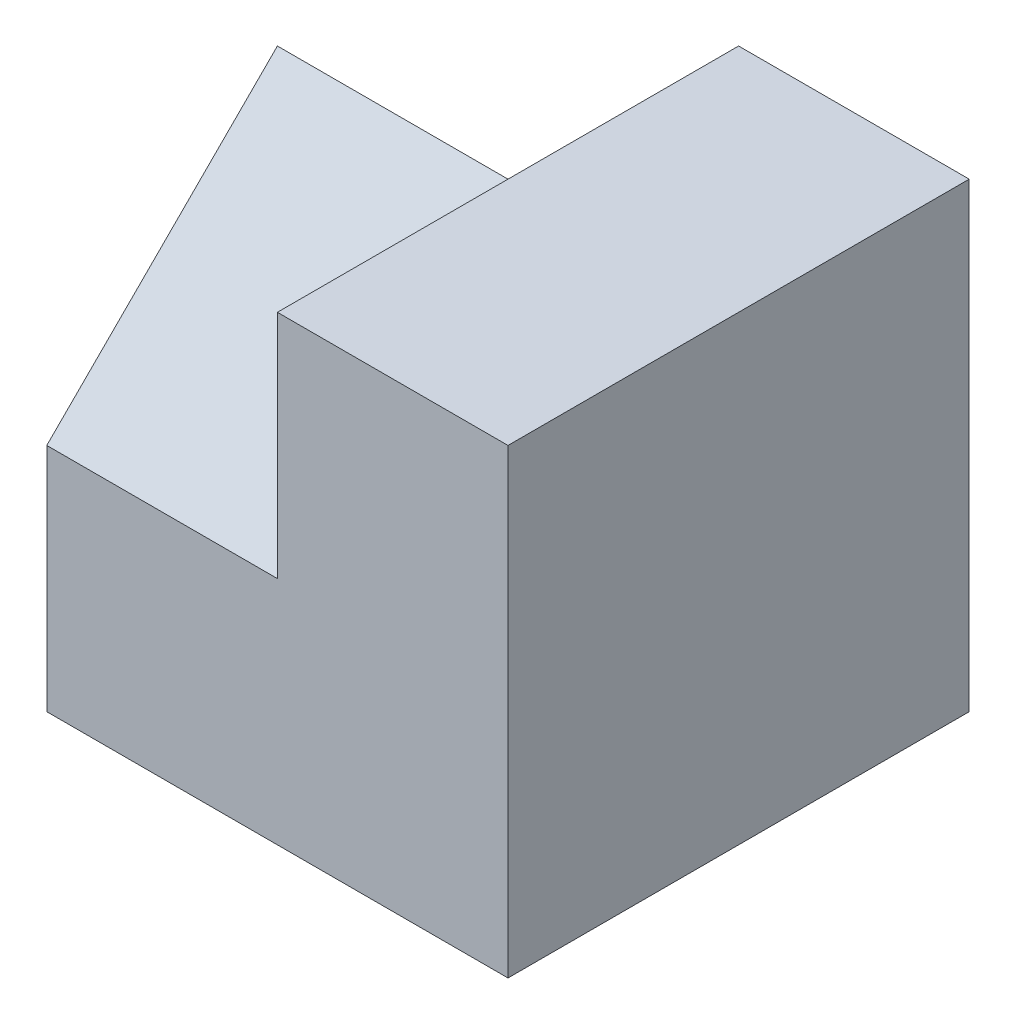
from build123d import *

# Parameters (mm, degrees)
SKETCH1_W           = 4
SKETCH1_H           = 4
BOSS_EXTRUDE1_DEPTH = 4
CUT_EXTRUDE1_DEPTH  = 2


with BuildPart() as part:
    # Sketch1 → Boss-Extrude1 (new body)
    with BuildSketch(Plane(origin=(0, 0, 0), x_dir=(1, 0, 0), z_dir=(0, 1, 0))):
        Rectangle(SKETCH1_W, SKETCH1_H)
    extrude(amount=BOSS_EXTRUDE1_DEPTH)

    # Sketch2 → Cut-Extrude1 (cut)
    with BuildSketch(Plane.ZY.offset(2)):
        Polygon((-2, 2), (0, 4), (-2, 4), align=None)
        Polygon((0, 4), (2, 2), (2, 4), align=None)
    extrude(amount=-CUT_EXTRUDE1_DEPTH, mode=Mode.SUBTRACT)


solid = part.part
